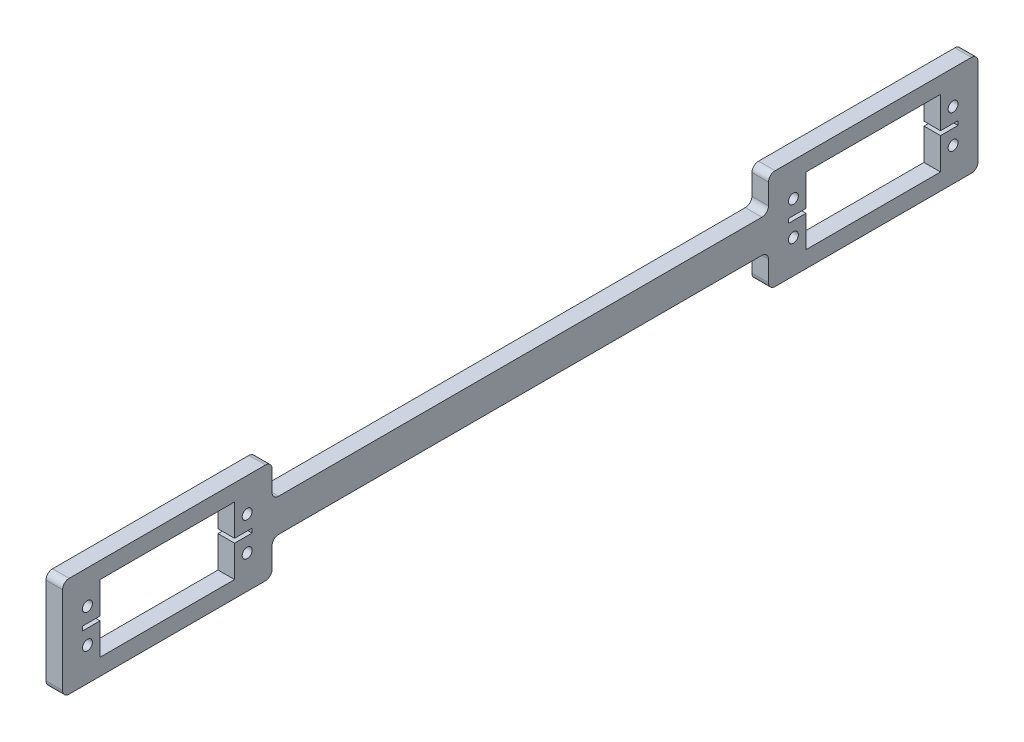
from build123d import *

# Parameters (mm, degrees)
BOSS_EXTRUDE1_DEPTH = 5
SKETCH1_R           = 1.5
SKETCH1_W           = 40.64
SKETCH1_H           = 20.32
CUT_EXTRUDE7_DEPTH  = 246.469607284
FILLET1_R           = 2
SKETCH4_W           = 5.3
SKETCH4_H           = 1.27
CUT_EXTRUDE8_DEPTH  = 246.469607284
SKETCH5_W           = 5.3
SKETCH5_H           = 1.27
CUT_EXTRUDE9_DEPTH  = 246.469607284


with BuildPart() as part:
    # Sketch2 → Boss-Extrude1 (new body)
    with BuildSketch(Plane(origin=(0, 0, 0), x_dir=(0, 0, -1), z_dir=(1, 0, 0))):
        Polygon((31.65, -15.16), (31.65, -5), (181.65, -5), (181.65, -15.16), (244.95, -15.16), (244.95, 15.16), (181.65, 15.16), (181.65, 5), (31.65, 5), (31.65, 15.16), (-31.65, 15.16), (-31.65, -15.16), align=None)
    extrude(amount=BOSS_EXTRUDE1_DEPTH)

    # Sketch1 → Cut-Extrude7 (cut, through all)
    with BuildSketch(Plane(origin=(0, 0, 0), x_dir=(0, 0, -1), z_dir=(1, 0, 0))):
        with Locations((-24.13, 5.08)):
            Circle(SKETCH1_R)
        with Locations((-24.13, -5.08)):
            Circle(SKETCH1_R)
        with Locations((24.13, 5.08)):
            Circle(SKETCH1_R)
        with Locations((24.13, -5.08)):
            Circle(SKETCH1_R)
        with Locations((189.17, -5.08)):
            Circle(SKETCH1_R)
        with Locations((189.17, 5.08)):
            Circle(SKETCH1_R)
        with Locations((237.43, -5.08)):
            Circle(SKETCH1_R)
        with Locations((237.43, 5.08)):
            Circle(SKETCH1_R)
        Rectangle(SKETCH1_W, SKETCH1_H)
        with Locations((213.3, 0)):
            Rectangle(SKETCH1_W, SKETCH1_H)
    extrude(amount=CUT_EXTRUDE7_DEPTH, mode=Mode.SUBTRACT)

    # Fillet1
    fillet1_edges = [part.edges().sort_by_distance(p)[0] for p in [
        (2.5, 15.16, 31.65),
        (2.5, 15.16, -31.65),
        (2.5, 5, -31.65),
        (2.5, -15.16, -31.65),
        (2.5, -5, -31.65),
        (2.5, -15.16, 31.65),
        (2.5, -5, -181.65),
        (2.5, -15.16, -181.65),
        (2.5, -15.16, -244.95),
        (2.5, 15.16, -244.95),
        (2.5, 5, -181.65),
        (2.5, 15.16, -181.65),
    ]]
    fillet(fillet1_edges, radius=FILLET1_R)

    # Sketch4 → Cut-Extrude8 (cut, through all)
    with BuildSketch(Plane(origin=(5, 0, 0), x_dir=(0, 0, -1), z_dir=(1, 0, 0))):
        with Locations((-22.97, 0)):
            Rectangle(SKETCH4_W, SKETCH4_H)
        with Locations((22.97, 0)):
            Rectangle(SKETCH4_W, SKETCH4_H)
    extrude(amount=-CUT_EXTRUDE8_DEPTH, mode=Mode.SUBTRACT)

    # Sketch5 → Cut-Extrude9 (cut, through all)
    with BuildSketch(Plane(origin=(5, 0, 0), x_dir=(0, 0, -1), z_dir=(1, 0, 0))):
        with Locations((236.27, 0)):
            Rectangle(SKETCH5_W, SKETCH5_H)
        with Locations((190.33, 0)):
            Rectangle(SKETCH5_W, SKETCH5_H)
    extrude(amount=-CUT_EXTRUDE9_DEPTH, mode=Mode.SUBTRACT)


solid = part.part
